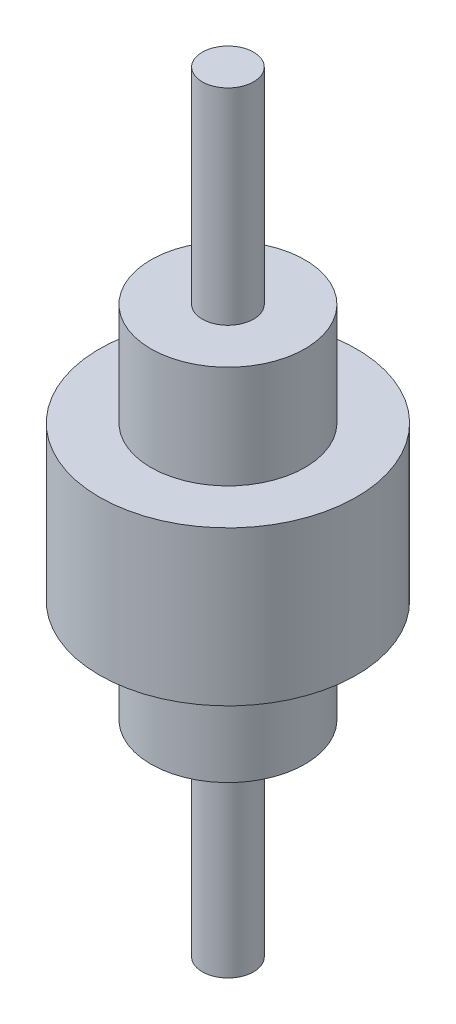
from build123d import *


with BuildPart() as part:
    # Sketch1 → Revolve2 (revolve)
    with BuildSketch(Plane.XY, mode=Mode.PRIVATE) as revolve2_sk:
        Polygon((10, 48.297053997), (30, 48.297053997), (30, 8.297053997), (50, 8.297053997), (50, -51.702946003), (30, -51.702946003), (30, -91.702946003), (10, -91.702946003), (10, -171.702946003), (0, -171.702946003), (0, 128.297053997), (10, 128.297053997), align=None)
    revolve(revolve2_sk.sketch.rotate(Axis((0, 128.297053997, 0), (0, -1, 0)), 90), axis=Axis((0, 128.297053997, 0), (0, -1, 0)))  # turned: the seam where the file's is


solid = part.part
